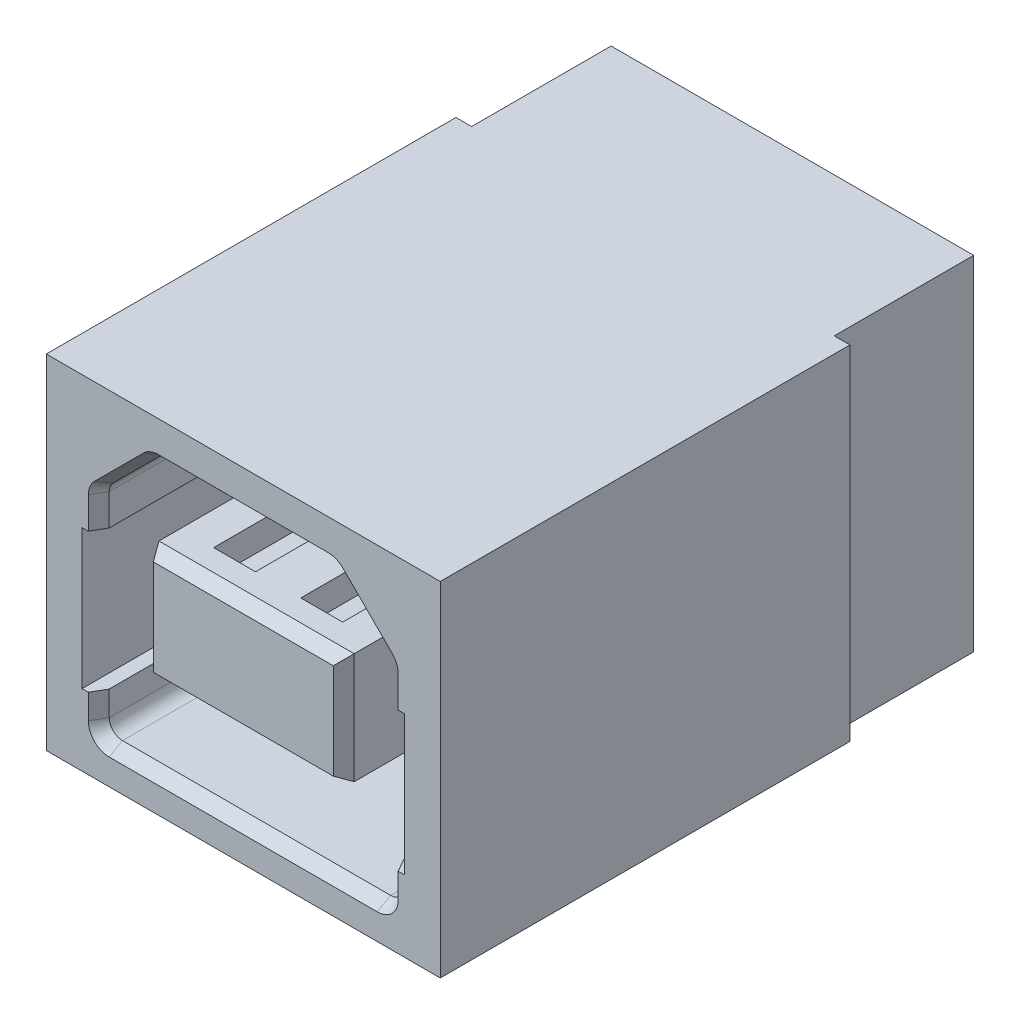
from build123d import *
from OCP.BRepFilletAPI import BRepFilletAPI_MakeChamfer

# Parameters (mm, degrees)
SKETCH1_W           = 11.3
SKETCH1_H           = 9.85
BOSS_EXTRUDE1_DEPTH = 15.75
SKETCH2_W           = 0.45
SKETCH2_H           = 4
CUT_EXTRUDE1_DEPTH  = 15.75
SKETCH3_W           = 5.6
SKETCH3_H           = 3.18
CUT_EXTRUDE2_DEPTH  = 8.38
CHAMFER1_SIZE       = 0.38
CHAMFER1_SIZE2      = 0.219393102
CHAMFER2_SIZE       = 0.38
CHAMFER2_SIZE2      = 0.219393102
SKETCH4_W           = 1
SKETCH4_H           = 10.13
SKETCH4_H_2         = 8.63
BOSS_EXTRUDE2_DEPTH = 0.83
SKETCH5_W           = 1.2
SKETCH5_H           = 0.75
CUT_EXTRUDE3_DEPTH  = 19.829431749
SKETCH6_W           = 1.2
SKETCH6_H           = 6.44
CUT_EXTRUDE4_DEPTH  = 1.29
CUT_EXTRUDE5_DEPTH  = 2


with BuildPart() as part:
    # Sketch1 → Boss-Extrude1 (new body)
    with BuildSketch(Plane.XY.offset(-0.38)):
        with Locations((0, 5.325)):
            Rectangle(SKETCH1_W, SKETCH1_H)
    extrude(amount=-BOSS_EXTRUDE1_DEPTH)

    # Sketch2 → Cut-Extrude1 (cut)
    with BuildSketch(Plane(origin=(0, 10.25, 0), x_dir=(1, 0, 0), z_dir=(0, 1, 0))):
        with Locations((-5.425, 14.13)):
            Rectangle(SKETCH2_W, SKETCH2_H)
        with Locations((5.425, 14.13)):
            Rectangle(SKETCH2_W, SKETCH2_H)
    extrude(amount=-CUT_EXTRUDE1_DEPTH, mode=Mode.SUBTRACT)

    # Sketch3 → Cut-Extrude2 (cut)
    with BuildSketch(Plane.XY.offset(-0.38)):
        with BuildLine():
            Line((-4.225, 7.352598846), (-4.225, 6.45))
            Line((-4.225, 6.45), (-4.625, 6.45))
            Line((-4.625, 6.45), (-4.625, 2.45))
            Line((-4.625, 2.45), (-4.225, 2.45))
            Line((-4.225, 2.45), (-4.225, 1.74))
            ThreePointArc((-4.225, 1.74), (-4.113700577, 1.471299423), (-3.845, 1.36))
            Line((-3.845, 1.36), (3.845, 1.36))
            ThreePointArc((3.845, 1.36), (4.113700577, 1.471299423), (4.225, 1.74))
            Line((4.225, 1.74), (4.225, 2.45))
            Line((4.225, 2.45), (4.625, 2.45))
            Line((4.625, 2.45), (4.625, 6.45))
            Line((4.625, 6.45), (4.225, 6.45))
            Line((4.225, 6.45), (4.225, 7.352598846))
            ThreePointArc((4.225, 7.352598846), (4.196074222, 7.498018551), (4.113700577, 7.621299423))
            Line((4.113700577, 7.621299423), (2.706299423, 9.028700577))
            ThreePointArc((2.706299423, 9.028700577), (2.583018551, 9.111074222), (2.437598846, 9.14))
            Line((2.437598846, 9.14), (-2.437598846, 9.14))
            ThreePointArc((-2.437598846, 9.14), (-2.583018551, 9.111074222), (-2.706299423, 9.028700577))
            Line((-2.706299423, 9.028700577), (-4.113700577, 7.621299423))
            ThreePointArc((-4.113700577, 7.621299423), (-4.196074222, 7.498018551), (-4.225, 7.352598846))
        make_face()
        with Locations((0, 5.25)):
            Rectangle(SKETCH3_W, SKETCH3_H, mode=Mode.SUBTRACT)
    extrude(amount=-CUT_EXTRUDE2_DEPTH, mode=Mode.SUBTRACT)

    # Chamfer1: one chamfer whose edges measure the first distance from different faces: ONE call of the kernel's chamfer builder (chamfer() names one face for all edges)
    chamfer1_edges_1 = [part.edges().sort_by_distance(p)[0] for p in [
        (-2.8, 5.25, -0.38),
    ]]
    chamfer1_side_1 = [part.faces().sort_by_distance(p)[0] for p in [
        (-2.8, 5.25, -4.57),
    ]]
    chamfer1_edges_2 = [part.edges().sort_by_distance(p)[0] for p in [
        (0, 6.84, -0.38),
    ]]
    chamfer1_side_2 = [part.faces().sort_by_distance(p)[0] for p in [
        (0, 6.84, -4.57),
    ]]
    chamfer1_edges_3 = [part.edges().sort_by_distance(p)[0] for p in [
        (2.8, 5.25, -0.38),
    ]]
    chamfer1_side_3 = [part.faces().sort_by_distance(p)[0] for p in [
        (2.8, 5.25, -4.57),
    ]]
    chamfer1_edges_4 = [part.edges().sort_by_distance(p)[0] for p in [
        (0, 3.66, -0.38),
    ]]
    chamfer1_side_4 = [part.faces().sort_by_distance(p)[0] for p in [
        (0, 3.66, -4.57),
    ]]
    chamfer1 = BRepFilletAPI_MakeChamfer(part.part.solid().wrapped)
    for e in chamfer1_edges_1:
        chamfer1.Add(CHAMFER1_SIZE, CHAMFER1_SIZE2, e.wrapped, chamfer1_side_1[0].wrapped)  # the first distance lies on this face
    for e in chamfer1_edges_2:
        chamfer1.Add(CHAMFER1_SIZE, CHAMFER1_SIZE2, e.wrapped, chamfer1_side_2[0].wrapped)  # the first distance lies on this face
    for e in chamfer1_edges_3:
        chamfer1.Add(CHAMFER1_SIZE, CHAMFER1_SIZE2, e.wrapped, chamfer1_side_3[0].wrapped)  # the first distance lies on this face
    for e in chamfer1_edges_4:
        chamfer1.Add(CHAMFER1_SIZE, CHAMFER1_SIZE2, e.wrapped, chamfer1_side_4[0].wrapped)  # the first distance lies on this face
    add(Compound.cast(chamfer1.Shape()), mode=Mode.REPLACE)

    # Chamfer2: one chamfer whose edges measure the first distance from different faces: ONE call of the kernel's chamfer builder (chamfer() names one face for all edges)
    chamfer2_edges_1 = [part.edges().sort_by_distance(p)[0] for p in [
        (-4.196074222, 7.498018551, -0.38),
    ]]
    chamfer2_side_1 = [part.faces().sort_by_distance(p)[0] for p in [
        (-4.196074222, 7.498018551, -4.57),
    ]]
    chamfer2_edges_2 = [part.edges().sort_by_distance(p)[0] for p in [
        (-4.225, 6.901299423, -0.38),
    ]]
    chamfer2_side_2 = [part.faces().sort_by_distance(p)[0] for p in [
        (-4.225, 6.901299423, -4.57),
    ]]
    chamfer2_edges_3 = [part.edges().sort_by_distance(p)[0] for p in [
        (-4.225, 2.095, -0.38),
    ]]
    chamfer2_side_3 = [part.faces().sort_by_distance(p)[0] for p in [
        (-4.225, 2.095, -4.57),
    ]]
    chamfer2_edges_4 = [part.edges().sort_by_distance(p)[0] for p in [
        (-4.113700577, 1.471299423, -0.38),
    ]]
    chamfer2_side_4 = [part.faces().sort_by_distance(p)[0] for p in [
        (-4.113700577, 1.471299423, -4.57),
    ]]
    chamfer2_edges_5 = [part.edges().sort_by_distance(p)[0] for p in [
        (0, 1.36, -0.38),
    ]]
    chamfer2_side_5 = [part.faces().sort_by_distance(p)[0] for p in [
        (0, 1.36, -4.57),
    ]]
    chamfer2_edges_6 = [part.edges().sort_by_distance(p)[0] for p in [
        (4.113700577, 1.471299423, -0.38),
    ]]
    chamfer2_side_6 = [part.faces().sort_by_distance(p)[0] for p in [
        (4.113700577, 1.471299423, -4.57),
    ]]
    chamfer2_edges_7 = [part.edges().sort_by_distance(p)[0] for p in [
        (4.225, 2.095, -0.38),
    ]]
    chamfer2_side_7 = [part.faces().sort_by_distance(p)[0] for p in [
        (4.225, 2.095, -4.57),
    ]]
    chamfer2_edges_8 = [part.edges().sort_by_distance(p)[0] for p in [
        (4.225, 6.901299423, -0.38),
    ]]
    chamfer2_side_8 = [part.faces().sort_by_distance(p)[0] for p in [
        (4.225, 6.901299423, -4.57),
    ]]
    chamfer2_edges_9 = [part.edges().sort_by_distance(p)[0] for p in [
        (4.196074222, 7.498018551, -0.38),
    ]]
    chamfer2_side_9 = [part.faces().sort_by_distance(p)[0] for p in [
        (4.196074222, 7.498018551, -4.57),
    ]]
    chamfer2_edges_10 = [part.edges().sort_by_distance(p)[0] for p in [
        (3.41, 8.325, -0.38),
    ]]
    chamfer2_side_10 = [part.faces().sort_by_distance(p)[0] for p in [
        (3.41, 8.325, -4.57),
    ]]
    chamfer2_edges_11 = [part.edges().sort_by_distance(p)[0] for p in [
        (2.583018551, 9.111074222, -0.38),
    ]]
    chamfer2_side_11 = [part.faces().sort_by_distance(p)[0] for p in [
        (2.583018551, 9.111074222, -4.57),
    ]]
    chamfer2_edges_12 = [part.edges().sort_by_distance(p)[0] for p in [
        (0, 9.14, -0.38),
    ]]
    chamfer2_side_12 = [part.faces().sort_by_distance(p)[0] for p in [
        (0, 9.14, -4.57),
    ]]
    chamfer2_edges_13 = [part.edges().sort_by_distance(p)[0] for p in [
        (-2.583018551, 9.111074222, -0.38),
    ]]
    chamfer2_side_13 = [part.faces().sort_by_distance(p)[0] for p in [
        (-2.583018551, 9.111074222, -4.57),
    ]]
    chamfer2_edges_14 = [part.edges().sort_by_distance(p)[0] for p in [
        (-3.41, 8.325, -0.38),
    ]]
    chamfer2_side_14 = [part.faces().sort_by_distance(p)[0] for p in [
        (-3.41, 8.325, -4.57),
    ]]
    chamfer2 = BRepFilletAPI_MakeChamfer(part.part.solid().wrapped)
    for e in chamfer2_edges_1:
        chamfer2.Add(CHAMFER2_SIZE, CHAMFER2_SIZE2, e.wrapped, chamfer2_side_1[0].wrapped)  # the first distance lies on this face
    for e in chamfer2_edges_2:
        chamfer2.Add(CHAMFER2_SIZE, CHAMFER2_SIZE2, e.wrapped, chamfer2_side_2[0].wrapped)  # the first distance lies on this face
    for e in chamfer2_edges_3:
        chamfer2.Add(CHAMFER2_SIZE, CHAMFER2_SIZE2, e.wrapped, chamfer2_side_3[0].wrapped)  # the first distance lies on this face
    for e in chamfer2_edges_4:
        chamfer2.Add(CHAMFER2_SIZE, CHAMFER2_SIZE2, e.wrapped, chamfer2_side_4[0].wrapped)  # the first distance lies on this face
    for e in chamfer2_edges_5:
        chamfer2.Add(CHAMFER2_SIZE, CHAMFER2_SIZE2, e.wrapped, chamfer2_side_5[0].wrapped)  # the first distance lies on this face
    for e in chamfer2_edges_6:
        chamfer2.Add(CHAMFER2_SIZE, CHAMFER2_SIZE2, e.wrapped, chamfer2_side_6[0].wrapped)  # the first distance lies on this face
    for e in chamfer2_edges_7:
        chamfer2.Add(CHAMFER2_SIZE, CHAMFER2_SIZE2, e.wrapped, chamfer2_side_7[0].wrapped)  # the first distance lies on this face
    for e in chamfer2_edges_8:
        chamfer2.Add(CHAMFER2_SIZE, CHAMFER2_SIZE2, e.wrapped, chamfer2_side_8[0].wrapped)  # the first distance lies on this face
    for e in chamfer2_edges_9:
        chamfer2.Add(CHAMFER2_SIZE, CHAMFER2_SIZE2, e.wrapped, chamfer2_side_9[0].wrapped)  # the first distance lies on this face
    for e in chamfer2_edges_10:
        chamfer2.Add(CHAMFER2_SIZE, CHAMFER2_SIZE2, e.wrapped, chamfer2_side_10[0].wrapped)  # the first distance lies on this face
    for e in chamfer2_edges_11:
        chamfer2.Add(CHAMFER2_SIZE, CHAMFER2_SIZE2, e.wrapped, chamfer2_side_11[0].wrapped)  # the first distance lies on this face
    for e in chamfer2_edges_12:
        chamfer2.Add(CHAMFER2_SIZE, CHAMFER2_SIZE2, e.wrapped, chamfer2_side_12[0].wrapped)  # the first distance lies on this face
    for e in chamfer2_edges_13:
        chamfer2.Add(CHAMFER2_SIZE, CHAMFER2_SIZE2, e.wrapped, chamfer2_side_13[0].wrapped)  # the first distance lies on this face
    for e in chamfer2_edges_14:
        chamfer2.Add(CHAMFER2_SIZE, CHAMFER2_SIZE2, e.wrapped, chamfer2_side_14[0].wrapped)  # the first distance lies on this face
    add(Compound.cast(chamfer2.Shape()), mode=Mode.REPLACE)

    # Sketch4 → Boss-Extrude2 (add)
    with BuildSketch(Plane(origin=(0, 0.4, 0), x_dir=(-1, 0, 0), z_dir=(0, -1, 0))):
        with Locations((3.75, 11.065)):
            Rectangle(SKETCH4_W, SKETCH4_H)
        with Locations((0, 11.815)):
            Rectangle(SKETCH4_W, SKETCH4_H_2)
        with Locations((-3.75, 11.065)):
            Rectangle(SKETCH4_W, SKETCH4_H)
    extrude(amount=BOSS_EXTRUDE2_DEPTH)

    # Sketch5 → Cut-Extrude3 (cut, through all)
    with BuildSketch(Plane.XY.offset(-1.38)):
        with Locations((-1.25, 6.465)):
            Rectangle(SKETCH5_W, SKETCH5_H)
        with Locations((1.25, 6.465)):
            Rectangle(SKETCH5_W, SKETCH5_H)
        with Locations((1.25, 4.035)):
            Rectangle(SKETCH5_W, SKETCH5_H)
        with Locations((-1.25, 4.035)):
            Rectangle(SKETCH5_W, SKETCH5_H)
    extrude(amount=-CUT_EXTRUDE3_DEPTH, mode=Mode.SUBTRACT)

    # Sketch6 → Cut-Extrude4 (cut)
    with BuildSketch(Plane(origin=(0, 0, -16.13), x_dir=(-1, 0, 0), z_dir=(0, 0, -1))):
        with Locations((-1.25, 3.62)):
            Rectangle(SKETCH6_W, SKETCH6_H)
        with Locations((1.25, 3.62)):
            Rectangle(SKETCH6_W, SKETCH6_H)
    extrude(amount=-CUT_EXTRUDE4_DEPTH, mode=Mode.SUBTRACT)

    # Sketch7 → Cut-Extrude5 (cut)
    with BuildSketch(Plane(origin=(0, 0, -14.84), x_dir=(-1, 0, 0), z_dir=(0, 0, -1))):
        Polygon((-1.55, 2.66), (-1.55, 0), (-0.95, 0), (-0.95, 2.66), (-0.65, 2.66), (-0.65, 4.41), (-1.85, 4.41), (-1.85, 2.66), align=None)
        Polygon((0.95, 2.66), (0.95, 0), (1.55, 0), (1.55, 2.66), (1.85, 2.66), (1.85, 4.41), (0.65, 4.41), (0.65, 2.66), align=None)
    extrude(amount=-CUT_EXTRUDE5_DEPTH, mode=Mode.SUBTRACT)


solid = part.part
